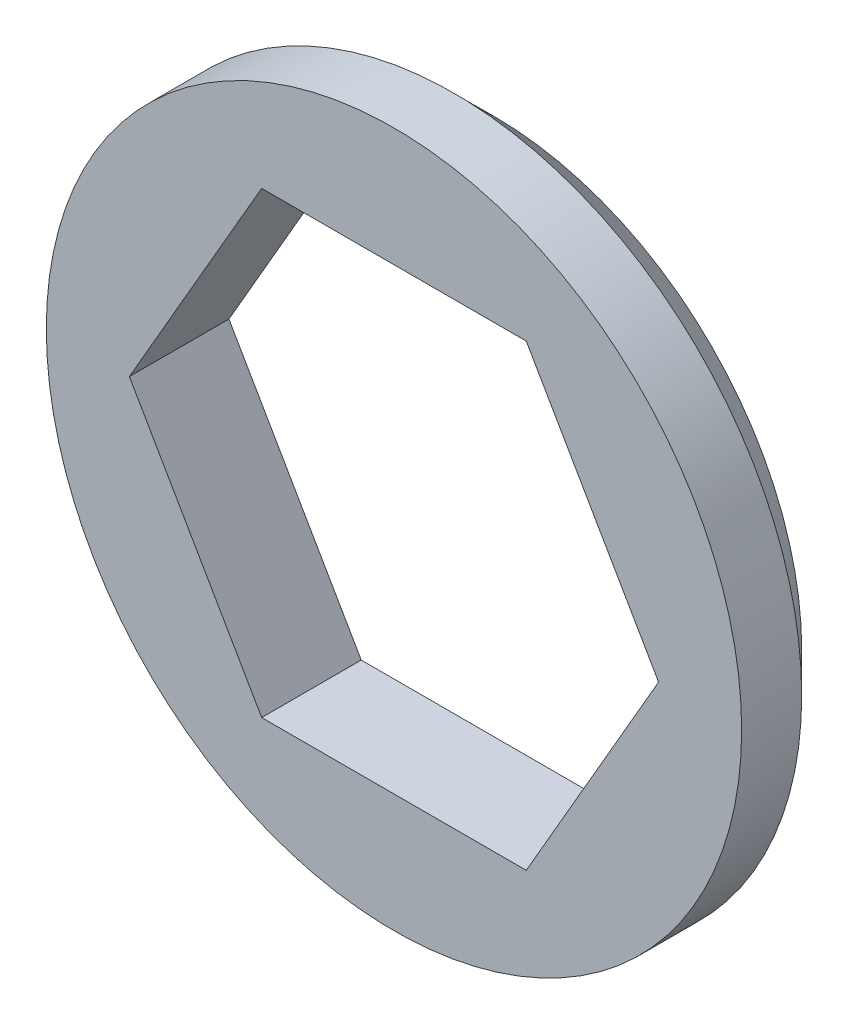
from build123d import *

# Parameters (mm, degrees)
SKETCH1_R           = 11
BOSS_EXTRUDE1_DEPTH = 3.15
CHAMFER1_SIZE       = 1.25


with BuildPart() as part:
    # Sketch1 → Boss-Extrude1 (new body)
    with BuildSketch(Plane.XY):
        Circle(SKETCH1_R)
        Polygon((8.371578903, 0), (4.185789452, 7.25), (-4.185789452, 7.25), (-8.371578903, 0), (-4.185789452, -7.25), (4.185789452, -7.25), align=None, mode=Mode.SUBTRACT)
    extrude(amount=BOSS_EXTRUDE1_DEPTH)

    # Chamfer1
    chamfer1_edges = [part.edges().sort_by_distance(p)[0] for p in [
        (-11, 0, 0),
    ]]
    chamfer(chamfer1_edges, length=CHAMFER1_SIZE)


solid = part.part
